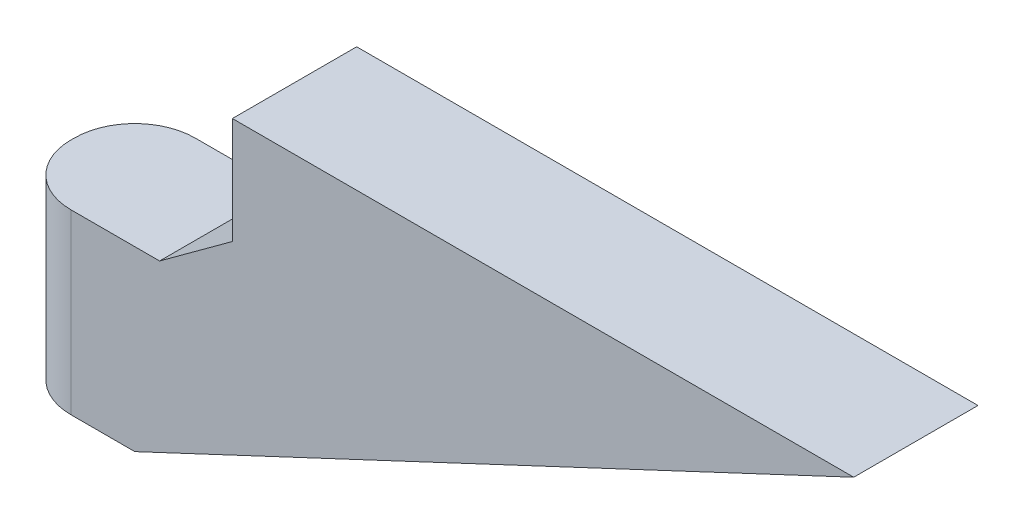
from build123d import *

# Parameters (mm, degrees)
BOSS_EXTRUDE1_DEPTH = 8.89
FILLET1_R           = 4.318


with BuildPart() as part:
    # Sketch1 → Boss-Extrude1 (new body)
    with BuildSketch(Plane.XY):
        Polygon((-19.4945, 0.635), (-30.1625, 0.635), (-30.1625, -12.065), (-21.2725, -12.065), (30.1625, 12.065), (-14.2875, 12.065), (-14.2875, 4.445), align=None)
    extrude(amount=BOSS_EXTRUDE1_DEPTH)

    # Fillet1
    fillet1_edges = [part.edges().sort_by_distance(p)[0] for p in [
        (-30.1625, -5.715, 8.89),
        (-30.1625, -5.715, 0),
    ]]
    fillet(fillet1_edges, radius=FILLET1_R)


solid = part.part
